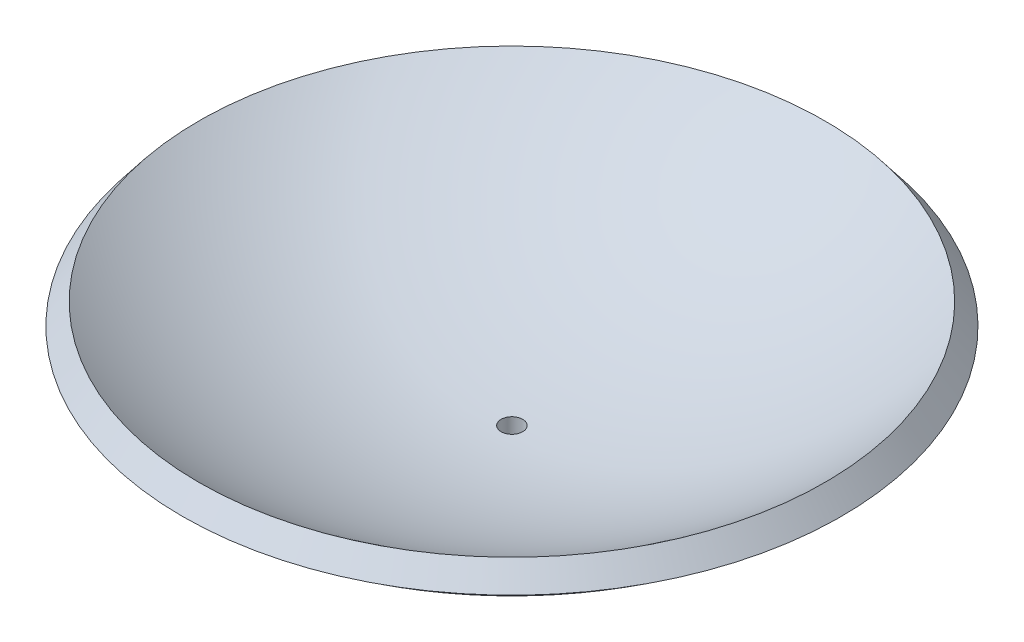
from build123d import *

# Parameters (mm, degrees)
F_1_4_20_TAPPED_HOLE1_D     = 5.1054
F_1_4_20_TAPPED_HOLE1_DEPTH = 12.7
F_1_4_20_TAPPED_HOLE1_TIP   = 1.533816902


with BuildPart() as part:
    # Sketch1 → Revolve1 (revolve)
    with BuildSketch(Plane.XY):
        with BuildLine():
            Line((0, 0), (-12.7, 0))
            Line((-12.7, 0), (-12.7, 6.35))
            ThreePointArc((-12.7, 6.35), (-47.166613701, 14.796863892), (-77.950620068, 32.450246618))
            Line((-77.950620068, 32.450246618), (-74.053089065, 37.463404513))
            ThreePointArc((-74.053089065, 37.463404513), (-39.144028919, 18.589929714), (0, 12.063404513))
            Line((0, 12.063404513), (0, 0))
        make_face()
    revolve(axis=Axis((0, 25.810843339, 0), (0, -1, 0)))

    # 1/4-20 Tapped Hole1
    with Locations(Plane(origin=(0, 0, 0), x_dir=(-1, 0, 0), z_dir=(0, -1, 0))):
        with Locations((0, 0)):
            Hole(F_1_4_20_TAPPED_HOLE1_D / 2, depth=F_1_4_20_TAPPED_HOLE1_DEPTH)
            with Locations((0, 0, -(F_1_4_20_TAPPED_HOLE1_DEPTH + F_1_4_20_TAPPED_HOLE1_TIP / 2))):  # 118° drill point
                Cone(0, F_1_4_20_TAPPED_HOLE1_D / 2, F_1_4_20_TAPPED_HOLE1_TIP, mode=Mode.SUBTRACT)


solid = part.part
